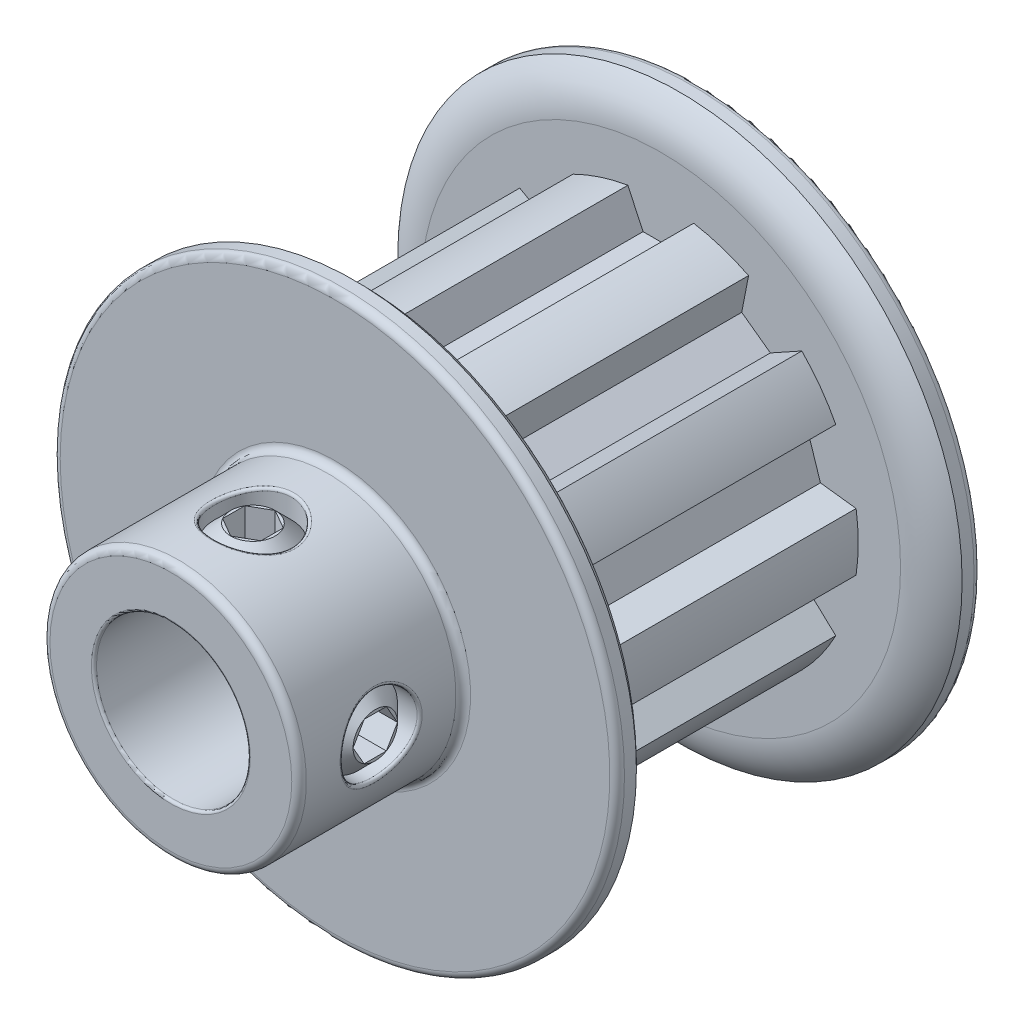
from build123d import *

# Parameters (mm, degrees)
CUT_EXTRUDE1_START = -8.8
CUT_EXTRUDE1_DEPTH = 11.2
CIRPATTERN1_COUNT  = 10
SKETCH4_R          = 1.5
CUT_EXTRUDE2_DEPTH = 19.657170203
CUT_EXTRUDE3_DEPTH = 1.125
CIRPATTERN2_COUNT  = 2
CIRPATTERN2_ANGLE  = 90
FILLET1_R          = 0.285714286
FILLET2_R          = 0.1


with BuildPart() as part:
    # Sketch7 → Revolve1 (revolve)
    with BuildSketch(Plane(origin=(0, 0, 0), x_dir=(0, 0, -1), z_dir=(1, 0, 0)), mode=Mode.PRIVATE) as revolve1_sk:
        with BuildLine():
            Line((-10.3, 3), (-10.3, 5))
            Line((-10.3, 5), (-3.9, 5))
            Line((-3.9, 5), (-3.9, 11))
            Line((-3.9, 11), (-3.15, 11))
            ThreePointArc((-3.15, 11), (-2.596287088, 10.255648454), (-2.4, 9.348935384))
            Line((-2.4, 9.348935384), (-2.4, 7.697870767))
            Line((-2.4, 7.697870767), (8.8, 7.697870767))
            Line((8.8, 7.697870767), (8.8, 9.348935384))
            ThreePointArc((8.8, 9.348935384), (8.996287088, 10.255648454), (9.55, 11))
            Line((9.55, 11), (10.3, 11))
            Line((10.3, 11), (10.3, 3))
            Line((10.3, 3), (-10.3, 3))
        make_face()
    revolve(revolve1_sk.sketch.rotate(Axis((0, 0, 10.3), (0, 0, -1)), 90), axis=Axis((0, 0, 10.3), (0, 0, -1)))

    # Sketch3 → Cut-Extrude1 (cut)
    with BuildSketch(Plane.XY.offset(CUT_EXTRUDE1_START)):
        with BuildLine():
            Line((-0.690489274, 6.32025), (0.690489274, 6.32025))
            Line((0.690489274, 6.32025), (1.2827, 7.59025))
            ThreePointArc((1.2827, 7.59025), (0, 7.697870767), (-1.2827, 7.59025))
            Line((-1.2827, 7.59025), (-0.690489274, 6.32025))
        make_face()
    cut_extrude1 = extrude(amount=CUT_EXTRUDE1_DEPTH, mode=Mode.SUBTRACT)

    # CirPattern1: Cut-Extrude1 ×10 about axis
    cirpattern1_axis = Axis((0, 0, 0), (0, 0, 1))
    for i in range(1, CIRPATTERN1_COUNT):
        add(cut_extrude1.rotate(cirpattern1_axis, i * 360 / CIRPATTERN1_COUNT), mode=Mode.SUBTRACT)

    # Sketch4 → Cut-Extrude2 (cut, through all)
    with BuildSketch(Plane(origin=(0, 0, 0), x_dir=(1, 0, 0), z_dir=(0, 1, 0))):
        with Locations(Location((0, -7.1, 0), (0, 0, 90))):
            Circle(SKETCH4_R)
    cut_extrude2 = extrude(amount=CUT_EXTRUDE2_DEPTH, mode=Mode.SUBTRACT)

    # Sketch5 → Revolve2 (revolve)
    with BuildSketch(Plane.XY.offset(7.1), mode=Mode.PRIVATE) as revolve2_sk:
        Polygon((0, 4.769696007), (0, 3), (-0.865, 3), (-1.5, 3.635), (-1.5, 4.134696007), (-0.865, 4.769696007), align=None)
    revolve2 = revolve(revolve2_sk.sketch.rotate(Axis((0, 0, 7.1), (0, 1, 0)), 270), axis=Axis((0, 0, 7.1), (0, 1, 0)))

    # Sketch6 → Cut-Extrude3 (cut)
    with BuildSketch(Plane(origin=(0, 4.769696007, 0), x_dir=(-1, 0, 0), z_dir=(0, -1, 0))):
        Polygon((0, -6.233974596), (-0.75, -6.666987298), (-0.75, -7.533012702), (0, -7.966025404), (0.75, -7.533012702), (0.75, -6.666987298), align=None)
    cut_extrude3 = extrude(amount=CUT_EXTRUDE3_DEPTH, mode=Mode.SUBTRACT)

    # CirPattern2: Cut-Extrude2, Revolve2, Cut-Extrude3 ×2 about axis
    cirpattern2_axis = Axis((0, 0, 0), (0, 0, -1))
    add([cut_extrude2.rotate(cirpattern2_axis, i * CIRPATTERN2_ANGLE / (CIRPATTERN2_COUNT - 1)) for i in range(1, CIRPATTERN2_COUNT)], mode=Mode.SUBTRACT)
    add([revolve2.rotate(cirpattern2_axis, i * CIRPATTERN2_ANGLE / (CIRPATTERN2_COUNT - 1)) for i in range(1, CIRPATTERN2_COUNT)])
    add([cut_extrude3.rotate(cirpattern2_axis, i * CIRPATTERN2_ANGLE / (CIRPATTERN2_COUNT - 1)) for i in range(1, CIRPATTERN2_COUNT)], mode=Mode.SUBTRACT)

    # Fillet1
    fillet1_edges = [part.edges().sort_by_distance(p)[0] for p in [
        (-11, 0, -10.3),
        (-5, 0, 10.3),
        (-5, 0, 3.9),
        (-11, 0, 3.9),
    ]]
    fillet(fillet1_edges, radius=FILLET1_R)

    # Fillet2
    fillet2_edges = [part.edges().sort_by_distance(p)[0] for p in [
        (-3, 0, -10.3),
        (-3e-09, 4.999999993, 8.600000008),
        (4.769696007, -1.5, 7.1),
        (-3, 0, 10.3),
    ]]
    fillet(fillet2_edges, radius=FILLET2_R)


solid = part.part
